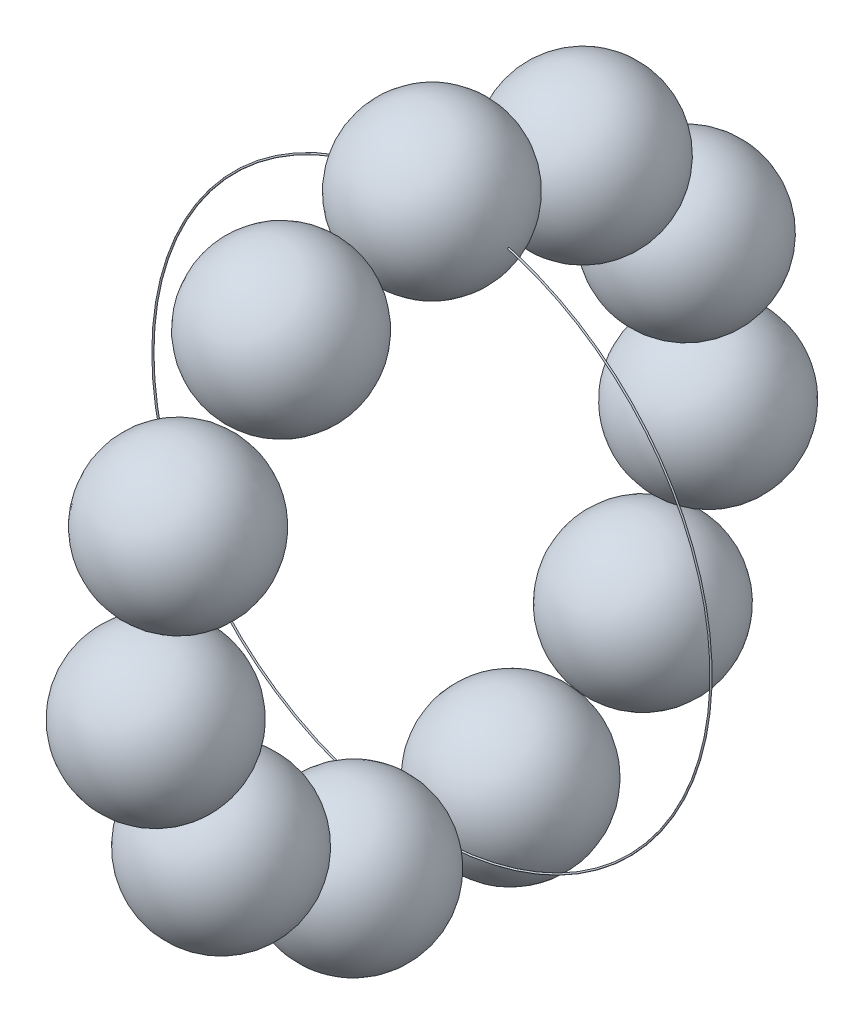
from build123d import *

# Parameters (mm, degrees)
CROQUIS4_R     = 0.05
MATRIZC1_COUNT = 11


with BuildPart() as part:
    # Croquis1 → Revolución1 (revolve)
    with BuildSketch(Plane.XY):
        with BuildLine():
            Line((0, 23), (0, 13))
            ThreePointArc((0, 13), (5, 18), (0, 23))
        make_face()
    revolve(axis=Axis((0, 0, 0), (0, 1, 0)))


with BuildPart() as body_2:
    # Croquis4 → Revolución2 (revolve)
    with BuildSketch(Plane(origin=(0, 0, 0), x_dir=(1, 0, 0), z_dir=(0, 1, 0))):
        with Locations((-18, 0)):
            Circle(CROQUIS4_R)
    revolve(axis=Axis((0, 0, -8.419286406), (0, 0, 1)))


with BuildPart() as matrizc1_1:
    # MatrizC1: pattern copy
    add(part.part.rotate(Axis((0, 0, 0), (1, 0, 0)), 1 * 360 / MATRIZC1_COUNT))


with BuildPart() as matrizc1_2:
    # MatrizC1: pattern copy
    add(part.part.rotate(Axis((0, 0, 0), (1, 0, 0)), 2 * 360 / MATRIZC1_COUNT))


with BuildPart() as matrizc1_3:
    # MatrizC1: pattern copy
    add(part.part.rotate(Axis((0, 0, 0), (1, 0, 0)), 3 * 360 / MATRIZC1_COUNT))


with BuildPart() as matrizc1_4:
    # MatrizC1: pattern copy
    add(part.part.rotate(Axis((0, 0, 0), (1, 0, 0)), 4 * 360 / MATRIZC1_COUNT))


with BuildPart() as matrizc1_5:
    # MatrizC1: pattern copy
    add(part.part.rotate(Axis((0, 0, 0), (1, 0, 0)), 5 * 360 / MATRIZC1_COUNT))


with BuildPart() as matrizc1_6:
    # MatrizC1: pattern copy
    add(part.part.rotate(Axis((0, 0, 0), (1, 0, 0)), 6 * 360 / MATRIZC1_COUNT))


with BuildPart() as matrizc1_7:
    # MatrizC1: pattern copy
    add(part.part.rotate(Axis((0, 0, 0), (1, 0, 0)), 7 * 360 / MATRIZC1_COUNT))


with BuildPart() as matrizc1_8:
    # MatrizC1: pattern copy
    add(part.part.rotate(Axis((0, 0, 0), (1, 0, 0)), 8 * 360 / MATRIZC1_COUNT))


with BuildPart() as matrizc1_9:
    # MatrizC1: pattern copy
    add(part.part.rotate(Axis((0, 0, 0), (1, 0, 0)), 9 * 360 / MATRIZC1_COUNT))


with BuildPart() as matrizc1_10:
    # MatrizC1: pattern copy
    add(part.part.rotate(Axis((0, 0, 0), (1, 0, 0)), 10 * 360 / MATRIZC1_COUNT))


solid = Compound([part.part, body_2.part, matrizc1_1.part, matrizc1_2.part, matrizc1_3.part, matrizc1_4.part, matrizc1_5.part, matrizc1_6.part, matrizc1_7.part, matrizc1_8.part, matrizc1_9.part, matrizc1_10.part])
